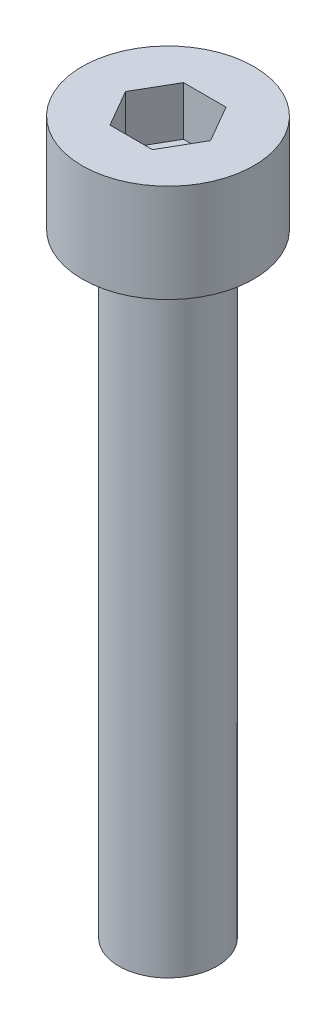
from build123d import *

# Parameters (mm, degrees)
SKETCH_1_R            = 3.5
EXTRUDE_246_DEPTH     = 4
CUT_EXTRUDE_376_DEPTH = 2
SKETCH_3_R            = 2
EXTRUDE_477_DEPTH     = 25


with BuildPart() as part:
    # 草图1 → Extrude 246 (new body)
    with BuildSketch(Plane(origin=(0, 0, 0), x_dir=(1, 0, 0), z_dir=(0, 1, 0))):
        Circle(SKETCH_1_R)
    extrude(amount=EXTRUDE_246_DEPTH)

    # 草图2 → Cut-Extrude 376 (cut)
    with BuildSketch(Plane(origin=(0, 4, 0), x_dir=(1, 0, 0), z_dir=(0, 1, 0))):
        Polygon((1.732050808, 0), (0.866025404, 1.5), (-0.866025404, 1.5), (-1.732050808, 0), (-0.866025404, -1.5), (0.866025404, -1.5), align=None)
    extrude(amount=-CUT_EXTRUDE_376_DEPTH, mode=Mode.SUBTRACT)

    # 草图3 → Extrude 477 (add)
    with BuildSketch(Plane.XZ):
        Circle(SKETCH_3_R)
    extrude(amount=EXTRUDE_477_DEPTH)


solid = part.part
